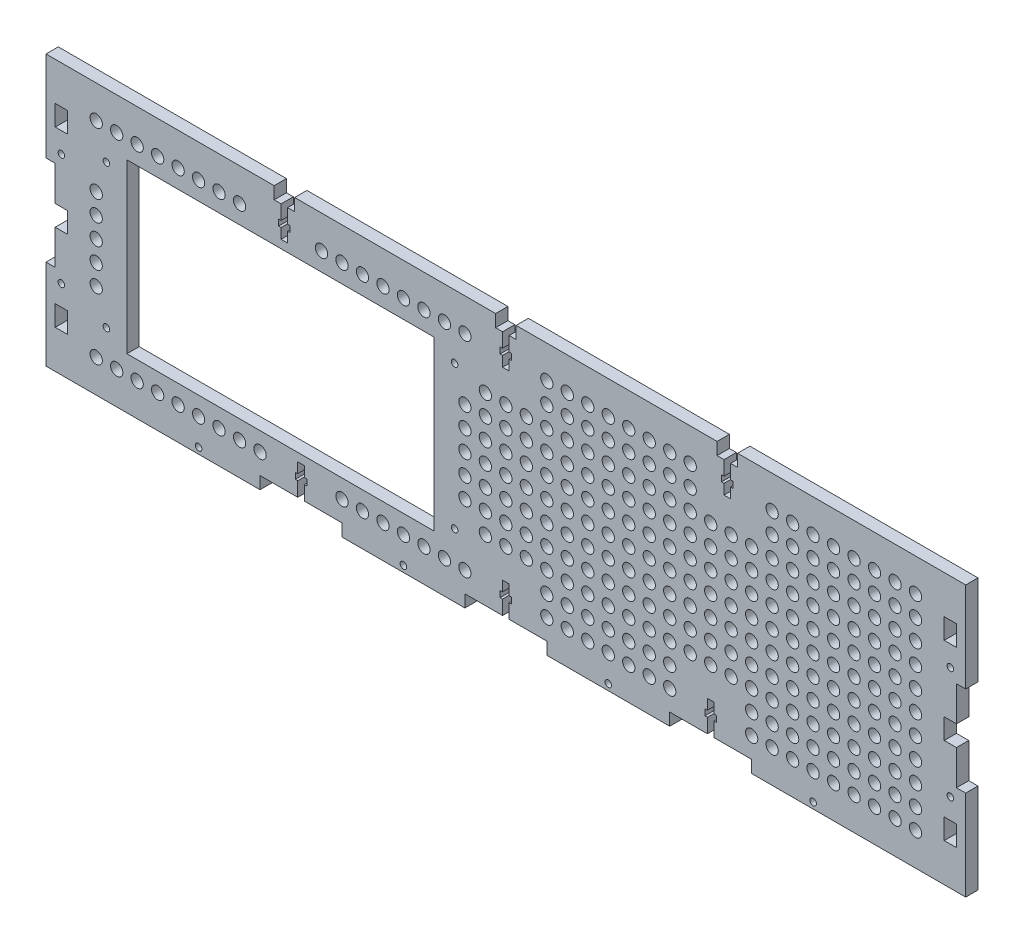
from build123d import *

# Parameters (mm, degrees)
SKETCH1_W           = 440
SKETCH1_H           = 132
BOSS_EXTRUDE1_DEPTH = 6
CUT_EXTRUDE1_REACH  = 8
SKETCH2_R           = 1.6
SKETCH2_W           = 6
SKETCH2_H           = 10
CUT_EXTRUDE2_REACH  = 8
SKETCH3_R           = 1.6
CUT_EXTRUDE3_REACH  = 8
SKETCH4_W           = 40
SKETCH4_H           = 6
SKETCH5_W           = 10
SKETCH5_H           = 6
CUT_EXTRUDE4_DEPTH  = 6
CUT_EXTRUDE5_REACH  = 8
SKETCH7_R           = 1.6
SKETCH7_W           = 150
SKETCH7_H           = 82
CUT_EXTRUDE6_DEPTH  = 7
SKETCH8_R           = 3
CUT_EXTRUDE7_DEPTH  = 7
SKETCH9_W           = 4.5
SKETCH9_H           = 44
BOSS_EXTRUDE2_DEPTH = 6


with BuildPart() as part:
    # Sketch1 → Boss-Extrude1 (new body)
    with BuildSketch(Plane.XY):
        Rectangle(SKETCH1_W, SKETCH1_H)
    extrude(amount=BOSS_EXTRUDE1_DEPTH)

    # Sketch2 → Cut-Extrude1 (cut, up to next)
    with BuildSketch(Plane(origin=(0, 0, 0), x_dir=(-1, 0, 0), z_dir=(0, 0, -1)), mode=Mode.PRIVATE) as cut_extrude1_sk1:
        with Locations((217, 27.332128782)):
            Circle(SKETCH2_R)
    cut_extrude1_tool1 = extrude(cut_extrude1_sk1.sketch, amount=-CUT_EXTRUDE1_REACH, mode=Mode.PRIVATE) & part.part
    add(cut_extrude1_tool1.solids().sort_by_distance((-217, 27.332129, 0))[0], mode=Mode.SUBTRACT)
    # Sketch2 → Cut-Extrude1 (cut, up to next)
    with BuildSketch(Plane(origin=(0, 0, 0), x_dir=(-1, 0, 0), z_dir=(0, 0, -1)), mode=Mode.PRIVATE) as cut_extrude1_sk2:
        with Locations((217, -27.332128782)):
            Circle(SKETCH2_R)
    cut_extrude1_tool2 = extrude(cut_extrude1_sk2.sketch, amount=-CUT_EXTRUDE1_REACH, mode=Mode.PRIVATE) & part.part
    add(cut_extrude1_tool2.solids().sort_by_distance((-217, -27.332129, 0))[0], mode=Mode.SUBTRACT)
    # Sketch2 → Cut-Extrude1 (cut, up to next)
    with BuildSketch(Plane(origin=(0, 0, 0), x_dir=(-1, 0, 0), z_dir=(0, 0, -1)), mode=Mode.PRIVATE) as cut_extrude1_sk3:
        with Locations((-217, 27.332128782)):
            Circle(SKETCH2_R)
    cut_extrude1_tool3 = extrude(cut_extrude1_sk3.sketch, amount=-CUT_EXTRUDE1_REACH, mode=Mode.PRIVATE) & part.part
    add(cut_extrude1_tool3.solids().sort_by_distance((217, 27.332129, 0))[0], mode=Mode.SUBTRACT)
    # Sketch2 → Cut-Extrude1 (cut, up to next)
    with BuildSketch(Plane(origin=(0, 0, 0), x_dir=(-1, 0, 0), z_dir=(0, 0, -1)), mode=Mode.PRIVATE) as cut_extrude1_sk4:
        with Locations((-217, -27.332128782)):
            Circle(SKETCH2_R)
    cut_extrude1_tool4 = extrude(cut_extrude1_sk4.sketch, amount=-CUT_EXTRUDE1_REACH, mode=Mode.PRIVATE) & part.part
    add(cut_extrude1_tool4.solids().sort_by_distance((217, -27.332129, 0))[0], mode=Mode.SUBTRACT)
    # Sketch2 → Cut-Extrude1 (cut, up to next)
    with BuildSketch(Plane(origin=(0, 0, 0), x_dir=(-1, 0, 0), z_dir=(0, 0, -1)), mode=Mode.PRIVATE) as cut_extrude1_sk5:
        with Locations((217, 42.332128782)):
            Rectangle(SKETCH2_W, SKETCH2_H)
    cut_extrude1_tool5 = extrude(cut_extrude1_sk5.sketch, amount=-CUT_EXTRUDE1_REACH, mode=Mode.PRIVATE) & part.part
    add(cut_extrude1_tool5.solids().sort_by_distance((-217, 42.332129, 0))[0], mode=Mode.SUBTRACT)
    # Sketch2 → Cut-Extrude1 (cut, up to next)
    with BuildSketch(Plane(origin=(0, 0, 0), x_dir=(-1, 0, 0), z_dir=(0, 0, -1)), mode=Mode.PRIVATE) as cut_extrude1_sk6:
        with Locations((217, -42.332128782)):
            Rectangle(SKETCH2_W, SKETCH2_H)
    cut_extrude1_tool6 = extrude(cut_extrude1_sk6.sketch, amount=-CUT_EXTRUDE1_REACH, mode=Mode.PRIVATE) & part.part
    add(cut_extrude1_tool6.solids().sort_by_distance((-217, -42.332129, 0))[0], mode=Mode.SUBTRACT)
    # Sketch2 → Cut-Extrude1 (cut, up to next)
    with BuildSketch(Plane(origin=(0, 0, 0), x_dir=(-1, 0, 0), z_dir=(0, 0, -1)), mode=Mode.PRIVATE) as cut_extrude1_sk7:
        with Locations((-217, -42.332128782)):
            Rectangle(SKETCH2_W, SKETCH2_H)
    cut_extrude1_tool7 = extrude(cut_extrude1_sk7.sketch, amount=-CUT_EXTRUDE1_REACH, mode=Mode.PRIVATE) & part.part
    add(cut_extrude1_tool7.solids().sort_by_distance((217, -42.332129, 0))[0], mode=Mode.SUBTRACT)
    # Sketch2 → Cut-Extrude1 (cut, up to next)
    with BuildSketch(Plane(origin=(0, 0, 0), x_dir=(-1, 0, 0), z_dir=(0, 0, -1)), mode=Mode.PRIVATE) as cut_extrude1_sk8:
        with Locations((-217, 42.332128782)):
            Rectangle(SKETCH2_W, SKETCH2_H)
    cut_extrude1_tool8 = extrude(cut_extrude1_sk8.sketch, amount=-CUT_EXTRUDE1_REACH, mode=Mode.PRIVATE) & part.part
    add(cut_extrude1_tool8.solids().sort_by_distance((217, 42.332129, 0))[0], mode=Mode.SUBTRACT)
    # Sketch2 → Cut-Extrude1 (cut, up to next)
    with BuildSketch(Plane(origin=(0, 0, 0), x_dir=(-1, 0, 0), z_dir=(0, 0, -1)), mode=Mode.PRIVATE) as cut_extrude1_sk9:
        with Locations((217, 0)):
            Rectangle(SKETCH2_W, SKETCH2_H)
    cut_extrude1_tool9 = extrude(cut_extrude1_sk9.sketch, amount=-CUT_EXTRUDE1_REACH, mode=Mode.PRIVATE) & part.part
    add(cut_extrude1_tool9.solids().sort_by_distance((-217, 0, 0))[0], mode=Mode.SUBTRACT)
    # Sketch2 → Cut-Extrude1 (cut, up to next)
    with BuildSketch(Plane(origin=(0, 0, 0), x_dir=(-1, 0, 0), z_dir=(0, 0, -1)), mode=Mode.PRIVATE) as cut_extrude1_sk10:
        with Locations((-217, 0)):
            Rectangle(SKETCH2_W, SKETCH2_H)
    cut_extrude1_tool10 = extrude(cut_extrude1_sk10.sketch, amount=-CUT_EXTRUDE1_REACH, mode=Mode.PRIVATE) & part.part
    add(cut_extrude1_tool10.solids().sort_by_distance((217, 0, 0))[0], mode=Mode.SUBTRACT)

    # Sketch3 → Cut-Extrude2 (cut, up to next)
    with BuildSketch(Plane(origin=(0, 0, 0), x_dir=(-1, 0, 0), z_dir=(0, 0, -1)), mode=Mode.PRIVATE) as cut_extrude2_sk1:
        with Locations((-150, -63)):
            Circle(SKETCH3_R)
    cut_extrude2_tool1 = extrude(cut_extrude2_sk1.sketch, amount=-CUT_EXTRUDE2_REACH, mode=Mode.PRIVATE) & part.part
    add(cut_extrude2_tool1.solids().sort_by_distance((150, -63, 0))[0], mode=Mode.SUBTRACT)
    # Sketch3 → Cut-Extrude2 (cut, up to next)
    with BuildSketch(Plane(origin=(0, 0, 0), x_dir=(-1, 0, 0), z_dir=(0, 0, -1)), mode=Mode.PRIVATE) as cut_extrude2_sk2:
        with Locations((-50, -63)):
            Circle(SKETCH3_R)
    cut_extrude2_tool2 = extrude(cut_extrude2_sk2.sketch, amount=-CUT_EXTRUDE2_REACH, mode=Mode.PRIVATE) & part.part
    add(cut_extrude2_tool2.solids().sort_by_distance((50, -63, 0))[0], mode=Mode.SUBTRACT)
    # Sketch3 → Cut-Extrude2 (cut, up to next)
    with BuildSketch(Plane(origin=(0, 0, 0), x_dir=(-1, 0, 0), z_dir=(0, 0, -1)), mode=Mode.PRIVATE) as cut_extrude2_sk3:
        with Locations((50, -63)):
            Circle(SKETCH3_R)
    cut_extrude2_tool3 = extrude(cut_extrude2_sk3.sketch, amount=-CUT_EXTRUDE2_REACH, mode=Mode.PRIVATE) & part.part
    add(cut_extrude2_tool3.solids().sort_by_distance((-50, -63, 0))[0], mode=Mode.SUBTRACT)
    # Sketch3 → Cut-Extrude2 (cut, up to next)
    with BuildSketch(Plane(origin=(0, 0, 0), x_dir=(-1, 0, 0), z_dir=(0, 0, -1)), mode=Mode.PRIVATE) as cut_extrude2_sk4:
        with Locations((150, -63)):
            Circle(SKETCH3_R)
    cut_extrude2_tool4 = extrude(cut_extrude2_sk4.sketch, amount=-CUT_EXTRUDE2_REACH, mode=Mode.PRIVATE) & part.part
    add(cut_extrude2_tool4.solids().sort_by_distance((-150, -63, 0))[0], mode=Mode.SUBTRACT)

    # Sketch4 → Cut-Extrude3 (cut, up to next)
    with BuildSketch(Plane(origin=(0, 0, 0), x_dir=(-1, 0, 0), z_dir=(0, 0, -1)), mode=Mode.PRIVATE) as cut_extrude3_sk1:
        with Locations((100, -63)):
            Rectangle(SKETCH4_W, SKETCH4_H)
    cut_extrude3_tool1 = extrude(cut_extrude3_sk1.sketch, amount=-CUT_EXTRUDE3_REACH, mode=Mode.PRIVATE) & part.part
    add(cut_extrude3_tool1.solids().sort_by_distance((-100, -63, 0))[0], mode=Mode.SUBTRACT)
    # Sketch4 → Cut-Extrude3 (cut, up to next)
    with BuildSketch(Plane(origin=(0, 0, 0), x_dir=(-1, 0, 0), z_dir=(0, 0, -1)), mode=Mode.PRIVATE) as cut_extrude3_sk2:
        with Locations((0, -63)):
            Rectangle(SKETCH4_W, SKETCH4_H)
    cut_extrude3_tool2 = extrude(cut_extrude3_sk2.sketch, amount=-CUT_EXTRUDE3_REACH, mode=Mode.PRIVATE) & part.part
    add(cut_extrude3_tool2.solids().sort_by_distance((0, -63, 0))[0], mode=Mode.SUBTRACT)
    # Sketch4 → Cut-Extrude3 (cut, up to next)
    with BuildSketch(Plane(origin=(0, 0, 0), x_dir=(-1, 0, 0), z_dir=(0, 0, -1)), mode=Mode.PRIVATE) as cut_extrude3_sk3:
        with Locations((-100, -63)):
            Rectangle(SKETCH4_W, SKETCH4_H)
    cut_extrude3_tool3 = extrude(cut_extrude3_sk3.sketch, amount=-CUT_EXTRUDE3_REACH, mode=Mode.PRIVATE) & part.part
    add(cut_extrude3_tool3.solids().sort_by_distance((100, -63, 0))[0], mode=Mode.SUBTRACT)

    # Sketch5 → Cut-Extrude4 (cut)
    with BuildSketch(Plane(origin=(0, 66, 0), x_dir=(1, 0, 0), z_dir=(0, 1, 0))):
        with Locations((-108.125, -3)):
            Rectangle(SKETCH5_W, SKETCH5_H)
        with Locations((0, -3)):
            Rectangle(SKETCH5_W, SKETCH5_H)
        with Locations((108.125, -3)):
            Rectangle(SKETCH5_W, SKETCH5_H)
    extrude(amount=-CUT_EXTRUDE4_DEPTH, mode=Mode.SUBTRACT)

    # Sketch6 → Cut-Extrude5 (cut, up to next)
    with BuildSketch(Plane(origin=(0, 0, 0), x_dir=(-1, 0, 0), z_dir=(0, 0, -1)), mode=Mode.PRIVATE) as cut_extrude5_sk1:
        Polygon((-109.725, 60), (-109.725, 53), (-110.925, 53), (-110.925, 50), (-109.725, 50), (-109.725, 45), (-106.525, 45), (-106.525, 50), (-105.325, 50), (-105.325, 53), (-106.525, 53), (-106.525, 60), align=None)
    cut_extrude5_tool1 = extrude(cut_extrude5_sk1.sketch, amount=-CUT_EXTRUDE5_REACH, mode=Mode.PRIVATE) & part.part
    add(cut_extrude5_tool1.solids().sort_by_distance((108.125, 52.369565, 0))[0], mode=Mode.SUBTRACT)
    # Sketch6 → Cut-Extrude5 (cut, up to next)
    with BuildSketch(Plane(origin=(0, 0, 0), x_dir=(-1, 0, 0), z_dir=(0, 0, -1)), mode=Mode.PRIVATE) as cut_extrude5_sk2:
        Polygon((-1.595, 60), (-1.595, 53), (-2.795, 53), (-2.795, 50), (-1.595, 50), (-1.595, 45), (1.605, 45), (1.605, 50), (2.805, 50), (2.805, 53), (1.605, 53), (1.605, 60), align=None)
    cut_extrude5_tool2 = extrude(cut_extrude5_sk2.sketch, amount=-CUT_EXTRUDE5_REACH, mode=Mode.PRIVATE) & part.part
    add(cut_extrude5_tool2.solids().sort_by_distance((-0.005, 52.369565, 0))[0], mode=Mode.SUBTRACT)
    # Sketch6 → Cut-Extrude5 (cut, up to next)
    with BuildSketch(Plane(origin=(0, 0, 0), x_dir=(-1, 0, 0), z_dir=(0, 0, -1)), mode=Mode.PRIVATE) as cut_extrude5_sk3:
        Polygon((106.535, 60), (106.535, 53), (105.335, 53), (105.335, 50), (106.535, 50), (106.535, 45), (109.735, 45), (109.735, 50), (110.935, 50), (110.935, 53), (109.735, 53), (109.735, 60), align=None)
    cut_extrude5_tool3 = extrude(cut_extrude5_sk3.sketch, amount=-CUT_EXTRUDE5_REACH, mode=Mode.PRIVATE) & part.part
    add(cut_extrude5_tool3.solids().sort_by_distance((-108.135, 52.369565, 0))[0], mode=Mode.SUBTRACT)
    # Sketch6 → Cut-Extrude5 (cut, up to next)
    with BuildSketch(Plane(origin=(0, 0, 0), x_dir=(-1, 0, 0), z_dir=(0, 0, -1)), mode=Mode.PRIVATE) as cut_extrude5_sk4:
        Polygon((-98.4, -60), (-98.4, -53), (-97.2, -53), (-97.2, -50), (-98.4, -50), (-98.4, -45), (-101.6, -45), (-101.6, -50), (-102.8, -50), (-102.8, -53), (-101.6, -53), (-101.6, -60), align=None)
    cut_extrude5_tool4 = extrude(cut_extrude5_sk4.sketch, amount=-CUT_EXTRUDE5_REACH, mode=Mode.PRIVATE) & part.part
    add(cut_extrude5_tool4.solids().sort_by_distance((100, -52.369565, 0))[0], mode=Mode.SUBTRACT)
    # Sketch6 → Cut-Extrude5 (cut, up to next)
    with BuildSketch(Plane(origin=(0, 0, 0), x_dir=(-1, 0, 0), z_dir=(0, 0, -1)), mode=Mode.PRIVATE) as cut_extrude5_sk5:
        Polygon((1.6, -60), (1.6, -53), (2.8, -53), (2.8, -50), (1.6, -50), (1.6, -45), (-1.6, -45), (-1.6, -50), (-2.8, -50), (-2.8, -53), (-1.6, -53), (-1.6, -60), align=None)
    cut_extrude5_tool5 = extrude(cut_extrude5_sk5.sketch, amount=-CUT_EXTRUDE5_REACH, mode=Mode.PRIVATE) & part.part
    add(cut_extrude5_tool5.solids().sort_by_distance((0, -52.369565, 0))[0], mode=Mode.SUBTRACT)
    # Sketch6 → Cut-Extrude5 (cut, up to next)
    with BuildSketch(Plane(origin=(0, 0, 0), x_dir=(-1, 0, 0), z_dir=(0, 0, -1)), mode=Mode.PRIVATE) as cut_extrude5_sk6:
        Polygon((101.6, -60), (101.6, -53), (102.8, -53), (102.8, -50), (101.6, -50), (101.6, -45), (98.4, -45), (98.4, -50), (97.2, -50), (97.2, -53), (98.4, -53), (98.4, -60), align=None)
    cut_extrude5_tool6 = extrude(cut_extrude5_sk6.sketch, amount=-CUT_EXTRUDE5_REACH, mode=Mode.PRIVATE) & part.part
    add(cut_extrude5_tool6.solids().sort_by_distance((-100, -52.369565, 0))[0], mode=Mode.SUBTRACT)

    # Sketch7 → Cut-Extrude6 (cut, through all)
    with BuildSketch(Plane(origin=(0, 0, 0), x_dir=(-1, 0, 0), z_dir=(0, 0, -1))):
        with Locations((25, 35)):
            Circle(SKETCH7_R)
        with Locations((25, -35)):
            Circle(SKETCH7_R)
        with Locations((195, 35)):
            Circle(SKETCH7_R)
        with Locations((195, -35)):
            Circle(SKETCH7_R)
        with Locations((110, 0)):
            Rectangle(SKETCH7_W, SKETCH7_H)
    extrude(amount=-CUT_EXTRUDE6_DEPTH, mode=Mode.SUBTRACT)

    # Sketch8 → Cut-Extrude7 (cut, through all)
    with BuildSketch(Plane(origin=(0, 0, 0), x_dir=(-1, 0, 0), z_dir=(0, 0, -1))):
        with Locations((-200, 50)):
            Circle(SKETCH8_R)
        with Locations((-190, 50)):
            Circle(SKETCH8_R)
        with Locations((-180, 50)):
            Circle(SKETCH8_R)
        with Locations((-170, 50)):
            Circle(SKETCH8_R)
        with Locations((-160, 50)):
            Circle(SKETCH8_R)
        with Locations((-150, 50)):
            Circle(SKETCH8_R)
        with Locations((-140, 50)):
            Circle(SKETCH8_R)
        with Locations((-130, 50)):
            Circle(SKETCH8_R)
        with Locations((-90, 50)):
            Circle(SKETCH8_R)
        with Locations((-80, 50)):
            Circle(SKETCH8_R)
        with Locations((-70, 50)):
            Circle(SKETCH8_R)
        with Locations((-60, 50)):
            Circle(SKETCH8_R)
        with Locations((-50, 50)):
            Circle(SKETCH8_R)
        with Locations((-40, 50)):
            Circle(SKETCH8_R)
        with Locations((-30, 50)):
            Circle(SKETCH8_R)
        with Locations((-20, 50)):
            Circle(SKETCH8_R)
        with Locations((20, 50)):
            Circle(SKETCH8_R)
        with Locations((30, 50)):
            Circle(SKETCH8_R)
        with Locations((40, 50)):
            Circle(SKETCH8_R)
        with Locations((50, 50)):
            Circle(SKETCH8_R)
        with Locations((60, 50)):
            Circle(SKETCH8_R)
        with Locations((70, 50)):
            Circle(SKETCH8_R)
        with Locations((80, 50)):
            Circle(SKETCH8_R)
        with Locations((90, 50)):
            Circle(SKETCH8_R)
        with Locations((130, 50)):
            Circle(SKETCH8_R)
        with Locations((140, 50)):
            Circle(SKETCH8_R)
        with Locations((150, 50)):
            Circle(SKETCH8_R)
        with Locations((160, 50)):
            Circle(SKETCH8_R)
        with Locations((170, 50)):
            Circle(SKETCH8_R)
        with Locations((180, 50)):
            Circle(SKETCH8_R)
        with Locations((190, 50)):
            Circle(SKETCH8_R)
        with Locations((200, 50)):
            Circle(SKETCH8_R)
        with Locations((-190, 40)):
            Circle(SKETCH8_R)
        with Locations((-180, 40)):
            Circle(SKETCH8_R)
        with Locations((-170, 40)):
            Circle(SKETCH8_R)
        with Locations((-160, 40)):
            Circle(SKETCH8_R)
        with Locations((-150, 40)):
            Circle(SKETCH8_R)
        with Locations((-140, 40)):
            Circle(SKETCH8_R)
        with Locations((-130, 40)):
            Circle(SKETCH8_R)
        with Locations((-90, 40)):
            Circle(SKETCH8_R)
        with Locations((-80, 40)):
            Circle(SKETCH8_R)
        with Locations((-70, 40)):
            Circle(SKETCH8_R)
        with Locations((-60, 40)):
            Circle(SKETCH8_R)
        with Locations((-50, 40)):
            Circle(SKETCH8_R)
        with Locations((-40, 40)):
            Circle(SKETCH8_R)
        with Locations((-30, 40)):
            Circle(SKETCH8_R)
        with Locations((-20, 40)):
            Circle(SKETCH8_R)
        with Locations((-190, 30)):
            Circle(SKETCH8_R)
        with Locations((-180, 30)):
            Circle(SKETCH8_R)
        with Locations((-170, 30)):
            Circle(SKETCH8_R)
        with Locations((-160, 30)):
            Circle(SKETCH8_R)
        with Locations((-150, 30)):
            Circle(SKETCH8_R)
        with Locations((-140, 30)):
            Circle(SKETCH8_R)
        with Locations((-130, 30)):
            Circle(SKETCH8_R)
        with Locations((-120, 30)):
            Circle(SKETCH8_R)
        with Locations((-110, 30)):
            Circle(SKETCH8_R)
        with Locations((-100, 30)):
            Circle(SKETCH8_R)
        with Locations((-90, 30)):
            Circle(SKETCH8_R)
        with Locations((-80, 30)):
            Circle(SKETCH8_R)
        with Locations((-70, 30)):
            Circle(SKETCH8_R)
        with Locations((-60, 30)):
            Circle(SKETCH8_R)
        with Locations((-50, 30)):
            Circle(SKETCH8_R)
        with Locations((-40, 30)):
            Circle(SKETCH8_R)
        with Locations((-30, 30)):
            Circle(SKETCH8_R)
        with Locations((-20, 30)):
            Circle(SKETCH8_R)
        with Locations((-10, 30)):
            Circle(SKETCH8_R)
        with Locations((0, 30)):
            Circle(SKETCH8_R)
        with Locations((10, 30)):
            Circle(SKETCH8_R)
        with Locations((-190, 20)):
            Circle(SKETCH8_R)
        with Locations((-180, 20)):
            Circle(SKETCH8_R)
        with Locations((-170, 20)):
            Circle(SKETCH8_R)
        with Locations((-160, 20)):
            Circle(SKETCH8_R)
        with Locations((-150, 20)):
            Circle(SKETCH8_R)
        with Locations((-140, 20)):
            Circle(SKETCH8_R)
        with Locations((-130, 20)):
            Circle(SKETCH8_R)
        with Locations((-120, 20)):
            Circle(SKETCH8_R)
        with Locations((-110, 20)):
            Circle(SKETCH8_R)
        with Locations((-100, 20)):
            Circle(SKETCH8_R)
        with Locations((-90, 20)):
            Circle(SKETCH8_R)
        with Locations((-80, 20)):
            Circle(SKETCH8_R)
        with Locations((-70, 20)):
            Circle(SKETCH8_R)
        with Locations((-60, 20)):
            Circle(SKETCH8_R)
        with Locations((-50, 20)):
            Circle(SKETCH8_R)
        with Locations((-40, 20)):
            Circle(SKETCH8_R)
        with Locations((-30, 20)):
            Circle(SKETCH8_R)
        with Locations((-20, 20)):
            Circle(SKETCH8_R)
        with Locations((-10, 20)):
            Circle(SKETCH8_R)
        with Locations((0, 20)):
            Circle(SKETCH8_R)
        with Locations((10, 20)):
            Circle(SKETCH8_R)
        with Locations((20, 20)):
            Circle(SKETCH8_R)
        with Locations((200, 20)):
            Circle(SKETCH8_R)
        with Locations((-190, 10)):
            Circle(SKETCH8_R)
        with Locations((-180, 10)):
            Circle(SKETCH8_R)
        with Locations((-170, 10)):
            Circle(SKETCH8_R)
        with Locations((-160, 10)):
            Circle(SKETCH8_R)
        with Locations((-150, 10)):
            Circle(SKETCH8_R)
        with Locations((-140, 10)):
            Circle(SKETCH8_R)
        with Locations((-130, 10)):
            Circle(SKETCH8_R)
        with Locations((-120, 10)):
            Circle(SKETCH8_R)
        with Locations((-110, 10)):
            Circle(SKETCH8_R)
        with Locations((-100, 10)):
            Circle(SKETCH8_R)
        with Locations((-90, 10)):
            Circle(SKETCH8_R)
        with Locations((-80, 10)):
            Circle(SKETCH8_R)
        with Locations((-70, 10)):
            Circle(SKETCH8_R)
        with Locations((-60, 10)):
            Circle(SKETCH8_R)
        with Locations((-50, 10)):
            Circle(SKETCH8_R)
        with Locations((-40, 10)):
            Circle(SKETCH8_R)
        with Locations((-30, 10)):
            Circle(SKETCH8_R)
        with Locations((-20, 10)):
            Circle(SKETCH8_R)
        with Locations((-10, 10)):
            Circle(SKETCH8_R)
        with Locations((0, 10)):
            Circle(SKETCH8_R)
        with Locations((10, 10)):
            Circle(SKETCH8_R)
        with Locations((20, 10)):
            Circle(SKETCH8_R)
        with Locations((200, 10)):
            Circle(SKETCH8_R)
        with Locations((-190, 0)):
            Circle(SKETCH8_R)
        with Locations((-180, 0)):
            Circle(SKETCH8_R)
        with Locations((-170, 0)):
            Circle(SKETCH8_R)
        with Locations((-160, 0)):
            Circle(SKETCH8_R)
        with Locations((-150, 0)):
            Circle(SKETCH8_R)
        with Locations((-140, 0)):
            Circle(SKETCH8_R)
        with Locations((-130, 0)):
            Circle(SKETCH8_R)
        with Locations((-120, 0)):
            Circle(SKETCH8_R)
        with Locations((-110, 0)):
            Circle(SKETCH8_R)
        with Locations((-100, 0)):
            Circle(SKETCH8_R)
        with Locations((-90, 0)):
            Circle(SKETCH8_R)
        with Locations((-80, 0)):
            Circle(SKETCH8_R)
        with Locations((-70, 0)):
            Circle(SKETCH8_R)
        with Locations((-60, 0)):
            Circle(SKETCH8_R)
        with Locations((-50, 0)):
            Circle(SKETCH8_R)
        with Locations((-40, 0)):
            Circle(SKETCH8_R)
        with Locations((-30, 0)):
            Circle(SKETCH8_R)
        with Locations((-20, 0)):
            Circle(SKETCH8_R)
        with Locations((-10, 0)):
            Circle(SKETCH8_R)
        Circle(SKETCH8_R)
        with Locations((10, 0)):
            Circle(SKETCH8_R)
        with Locations((20, 0)):
            Circle(SKETCH8_R)
        with Locations((200, 0)):
            Circle(SKETCH8_R)
        with Locations((-190, -10)):
            Circle(SKETCH8_R)
        with Locations((-180, -10)):
            Circle(SKETCH8_R)
        with Locations((-170, -10)):
            Circle(SKETCH8_R)
        with Locations((-160, -10)):
            Circle(SKETCH8_R)
        with Locations((-150, -10)):
            Circle(SKETCH8_R)
        with Locations((-140, -10)):
            Circle(SKETCH8_R)
        with Locations((-130, -10)):
            Circle(SKETCH8_R)
        with Locations((-120, -10)):
            Circle(SKETCH8_R)
        with Locations((-110, -10)):
            Circle(SKETCH8_R)
        with Locations((-100, -10)):
            Circle(SKETCH8_R)
        with Locations((-90, -10)):
            Circle(SKETCH8_R)
        with Locations((-80, -10)):
            Circle(SKETCH8_R)
        with Locations((-70, -10)):
            Circle(SKETCH8_R)
        with Locations((-60, -10)):
            Circle(SKETCH8_R)
        with Locations((-50, -10)):
            Circle(SKETCH8_R)
        with Locations((-40, -10)):
            Circle(SKETCH8_R)
        with Locations((-30, -10)):
            Circle(SKETCH8_R)
        with Locations((-20, -10)):
            Circle(SKETCH8_R)
        with Locations((-10, -10)):
            Circle(SKETCH8_R)
        with Locations((0, -10)):
            Circle(SKETCH8_R)
        with Locations((10, -10)):
            Circle(SKETCH8_R)
        with Locations((20, -10)):
            Circle(SKETCH8_R)
        with Locations((200, -10)):
            Circle(SKETCH8_R)
        with Locations((-190, -20)):
            Circle(SKETCH8_R)
        with Locations((-180, -20)):
            Circle(SKETCH8_R)
        with Locations((-170, -20)):
            Circle(SKETCH8_R)
        with Locations((-160, -20)):
            Circle(SKETCH8_R)
        with Locations((-150, -20)):
            Circle(SKETCH8_R)
        with Locations((-140, -20)):
            Circle(SKETCH8_R)
        with Locations((-130, -20)):
            Circle(SKETCH8_R)
        with Locations((-120, -20)):
            Circle(SKETCH8_R)
        with Locations((-110, -20)):
            Circle(SKETCH8_R)
        with Locations((-100, -20)):
            Circle(SKETCH8_R)
        with Locations((-90, -20)):
            Circle(SKETCH8_R)
        with Locations((-80, -20)):
            Circle(SKETCH8_R)
        with Locations((-70, -20)):
            Circle(SKETCH8_R)
        with Locations((-60, -20)):
            Circle(SKETCH8_R)
        with Locations((-50, -20)):
            Circle(SKETCH8_R)
        with Locations((-40, -20)):
            Circle(SKETCH8_R)
        with Locations((-30, -20)):
            Circle(SKETCH8_R)
        with Locations((-20, -20)):
            Circle(SKETCH8_R)
        with Locations((-10, -20)):
            Circle(SKETCH8_R)
        with Locations((0, -20)):
            Circle(SKETCH8_R)
        with Locations((10, -20)):
            Circle(SKETCH8_R)
        with Locations((20, -20)):
            Circle(SKETCH8_R)
        with Locations((200, -20)):
            Circle(SKETCH8_R)
        with Locations((-190, -30)):
            Circle(SKETCH8_R)
        with Locations((-180, -30)):
            Circle(SKETCH8_R)
        with Locations((-170, -30)):
            Circle(SKETCH8_R)
        with Locations((-160, -30)):
            Circle(SKETCH8_R)
        with Locations((-150, -30)):
            Circle(SKETCH8_R)
        with Locations((-140, -30)):
            Circle(SKETCH8_R)
        with Locations((-130, -30)):
            Circle(SKETCH8_R)
        with Locations((-120, -30)):
            Circle(SKETCH8_R)
        with Locations((-110, -30)):
            Circle(SKETCH8_R)
        with Locations((-100, -30)):
            Circle(SKETCH8_R)
        with Locations((-90, -30)):
            Circle(SKETCH8_R)
        with Locations((-80, -30)):
            Circle(SKETCH8_R)
        with Locations((-70, -30)):
            Circle(SKETCH8_R)
        with Locations((-60, -30)):
            Circle(SKETCH8_R)
        with Locations((-50, -30)):
            Circle(SKETCH8_R)
        with Locations((-40, -30)):
            Circle(SKETCH8_R)
        with Locations((-30, -30)):
            Circle(SKETCH8_R)
        with Locations((-20, -30)):
            Circle(SKETCH8_R)
        with Locations((-10, -30)):
            Circle(SKETCH8_R)
        with Locations((0, -30)):
            Circle(SKETCH8_R)
        with Locations((10, -30)):
            Circle(SKETCH8_R)
        with Locations((-190, -40)):
            Circle(SKETCH8_R)
        with Locations((-180, -40)):
            Circle(SKETCH8_R)
        with Locations((-170, -40)):
            Circle(SKETCH8_R)
        with Locations((-160, -40)):
            Circle(SKETCH8_R)
        with Locations((-150, -40)):
            Circle(SKETCH8_R)
        with Locations((-140, -40)):
            Circle(SKETCH8_R)
        with Locations((-130, -40)):
            Circle(SKETCH8_R)
        with Locations((-120, -40)):
            Circle(SKETCH8_R)
        with Locations((-80, -40)):
            Circle(SKETCH8_R)
        with Locations((-70, -40)):
            Circle(SKETCH8_R)
        with Locations((-60, -40)):
            Circle(SKETCH8_R)
        with Locations((-50, -40)):
            Circle(SKETCH8_R)
        with Locations((-40, -40)):
            Circle(SKETCH8_R)
        with Locations((-30, -40)):
            Circle(SKETCH8_R)
        with Locations((-20, -40)):
            Circle(SKETCH8_R)
        with Locations((-190, -50)):
            Circle(SKETCH8_R)
        with Locations((-180, -50)):
            Circle(SKETCH8_R)
        with Locations((-170, -50)):
            Circle(SKETCH8_R)
        with Locations((-160, -50)):
            Circle(SKETCH8_R)
        with Locations((-150, -50)):
            Circle(SKETCH8_R)
        with Locations((-140, -50)):
            Circle(SKETCH8_R)
        with Locations((-130, -50)):
            Circle(SKETCH8_R)
        with Locations((-120, -50)):
            Circle(SKETCH8_R)
        with Locations((-80, -50)):
            Circle(SKETCH8_R)
        with Locations((-70, -50)):
            Circle(SKETCH8_R)
        with Locations((-60, -50)):
            Circle(SKETCH8_R)
        with Locations((-50, -50)):
            Circle(SKETCH8_R)
        with Locations((-40, -50)):
            Circle(SKETCH8_R)
        with Locations((-30, -50)):
            Circle(SKETCH8_R)
        with Locations((-20, -50)):
            Circle(SKETCH8_R)
        with Locations((20, -50)):
            Circle(SKETCH8_R)
        with Locations((30, -50)):
            Circle(SKETCH8_R)
        with Locations((40, -50)):
            Circle(SKETCH8_R)
        with Locations((50, -50)):
            Circle(SKETCH8_R)
        with Locations((60, -50)):
            Circle(SKETCH8_R)
        with Locations((70, -50)):
            Circle(SKETCH8_R)
        with Locations((80, -50)):
            Circle(SKETCH8_R)
        with Locations((120, -50)):
            Circle(SKETCH8_R)
        with Locations((130, -50)):
            Circle(SKETCH8_R)
        with Locations((140, -50)):
            Circle(SKETCH8_R)
        with Locations((150, -50)):
            Circle(SKETCH8_R)
        with Locations((160, -50)):
            Circle(SKETCH8_R)
        with Locations((170, -50)):
            Circle(SKETCH8_R)
        with Locations((180, -50)):
            Circle(SKETCH8_R)
        with Locations((190, -50)):
            Circle(SKETCH8_R)
        with Locations((200, -50)):
            Circle(SKETCH8_R)
        with Locations((-200, 40)):
            Circle(SKETCH8_R)
        with Locations((-200, 30)):
            Circle(SKETCH8_R)
        with Locations((-200, 20)):
            Circle(SKETCH8_R)
        with Locations((-200, 10)):
            Circle(SKETCH8_R)
        with Locations((-200, 0)):
            Circle(SKETCH8_R)
        with Locations((-200, -10)):
            Circle(SKETCH8_R)
        with Locations((-200, -20)):
            Circle(SKETCH8_R)
        with Locations((-200, -30)):
            Circle(SKETCH8_R)
        with Locations((-200, -40)):
            Circle(SKETCH8_R)
        with Locations((-200, -50)):
            Circle(SKETCH8_R)
    extrude(amount=-CUT_EXTRUDE7_DEPTH, mode=Mode.SUBTRACT)

    # Sketch9 → Boss-Extrude2 (add)
    with BuildSketch(Plane(origin=(0, 0, 0), x_dir=(-1, 0, 0), z_dir=(0, 0, -1))):
        with Locations((222.25, 44)):
            Rectangle(SKETCH9_W, SKETCH9_H)
        with Locations((222.25, -44)):
            Rectangle(SKETCH9_W, SKETCH9_H)
        with Locations((-222.25, -44)):
            Rectangle(SKETCH9_W, SKETCH9_H)
        with Locations((-222.25, 44)):
            Rectangle(SKETCH9_W, SKETCH9_H)
    extrude(amount=-BOSS_EXTRUDE2_DEPTH)


solid = part.part
